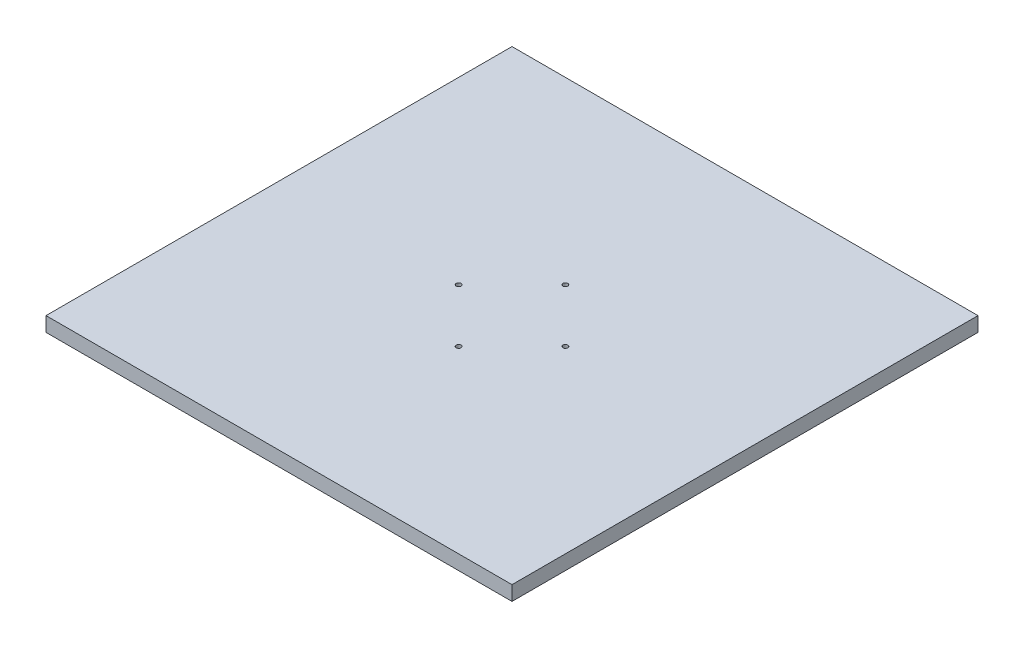
from build123d import *

# Parameters (mm, degrees)
SKETCH1_W           = 609.6
SKETCH1_H           = 609.6
BOSS_EXTRUDE1_DEPTH = 19.05
SKETCH2_R           = 3.175
CUT_EXTRUDE1_DEPTH  = 20.05
SKETCH3_R           = 8.765833612
CUT_EXTRUDE2_DEPTH  = 2.54
HOLE1_D             = 6.35
HOLE1_DEPTH         = 25.4
HOLE1_CBORE_D       = 19.05
HOLE1_CBORE_DEPTH   = 6.35


with BuildPart() as part:
    # Sketch1 → Boss-Extrude1 (new body)
    with BuildSketch(Plane(origin=(0, 0, 0), x_dir=(1, 0, 0), z_dir=(0, 1, 0))):
        with Locations((304.8, 304.8)):
            Rectangle(SKETCH1_W, SKETCH1_H)
    extrude(amount=BOSS_EXTRUDE1_DEPTH)

    # Sketch2 → Cut-Extrude1 (cut, through all)
    with BuildSketch(Plane(origin=(0, 19.05, 0), x_dir=(1, 0, 0), z_dir=(0, 1, 0))):
        with Locations((304.8, 374.65)):
            Circle(SKETCH2_R)
        with Locations((234.95, 304.8)):
            Circle(SKETCH2_R)
        with Locations((374.65, 304.8)):
            Circle(SKETCH2_R)
        with Locations((304.8, 234.95)):
            Circle(SKETCH2_R)
    extrude(amount=-CUT_EXTRUDE1_DEPTH, mode=Mode.SUBTRACT)

    # Sketch3 → Cut-Extrude2 (cut)
    with BuildSketch(Plane(origin=(0, 0, 0), x_dir=(1, 0, 0), z_dir=(0, 1, 0))):
        with Locations((304.8, 304.8)):
            Circle(SKETCH3_R)
    extrude(amount=CUT_EXTRUDE2_DEPTH, mode=Mode.SUBTRACT)

    # Hole1
    with Locations(Plane(origin=(0, 0, 0), x_dir=(-1, 0, 0), z_dir=(0, -1, 0))):
        with Locations((-234.95, 304.8), (-304.8, 234.95), (-374.65, 304.8), (-304.8, 374.65)):
            CounterBoreHole(HOLE1_D / 2, HOLE1_CBORE_D / 2, HOLE1_CBORE_DEPTH, depth=HOLE1_DEPTH)


solid = part.part
